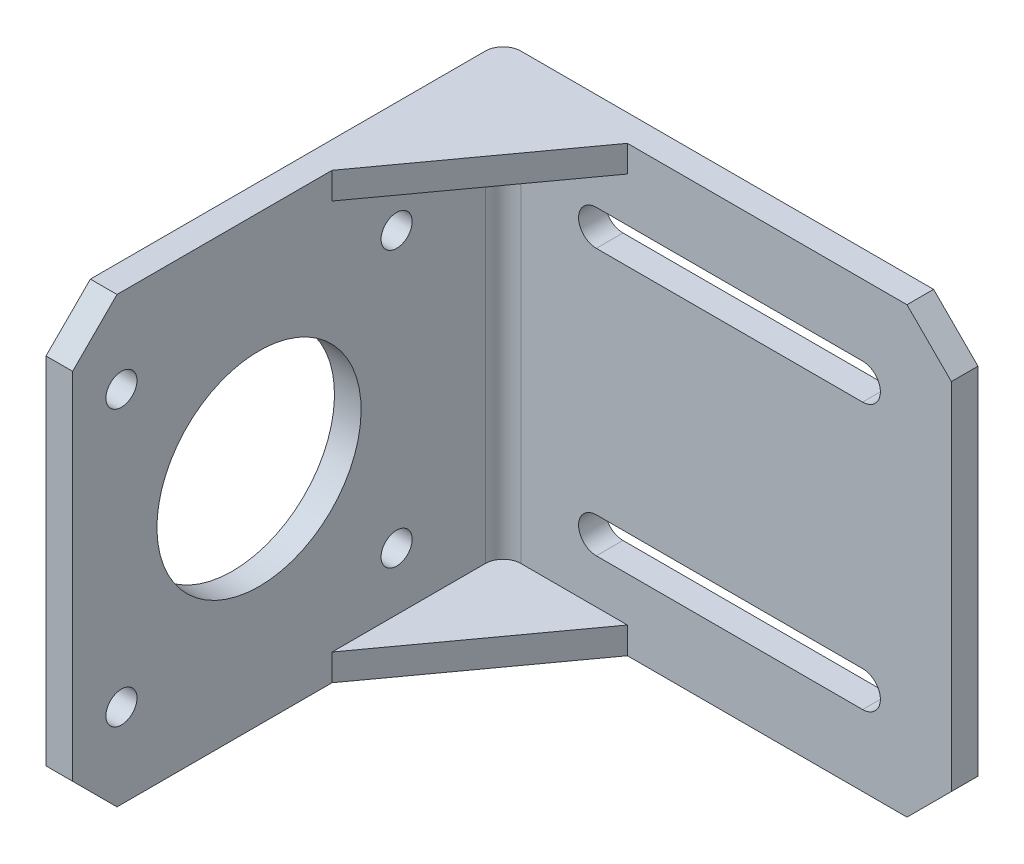
from build123d import *

# Parameters (mm, degrees)
SKETCH2_W           = 53.5
SKETCH2_H           = 50
BOSS_EXTRUDE1_DEPTH = 51.5
SKETCH3_W           = 50.5
SKETCH3_H           = 50
CUT_EXTRUDE1_DEPTH  = 48.5
CHAMFER1_SIZE       = 14
CHAMFER1_SIZE2      = 19.269346887
SKETCH4_W           = 48.5
SKETCH4_H           = 44
CUT_EXTRUDE2_DEPTH  = 50.5
SKETCH5_R           = 1.75
SKETCH5_R_2         = 11.5
CUT_EXTRUDE3_DEPTH  = 10
CUT_EXTRUDE4_DEPTH  = 10
CHAMFER2_SIZE       = 5
FILLET1_R           = 2


with BuildPart() as part:
    # Sketch2 → Boss-Extrude1 (new body)
    with BuildSketch(Plane.XY):
        Rectangle(SKETCH2_W, SKETCH2_H)
    extrude(amount=BOSS_EXTRUDE1_DEPTH)

    # Sketch3 → Cut-Extrude1 (cut)
    with BuildSketch(Plane.XY.offset(51.5)):
        with Locations((1.5, 0)):
            Rectangle(SKETCH3_W, SKETCH3_H)
    extrude(amount=-CUT_EXTRUDE1_DEPTH, mode=Mode.SUBTRACT)

    # Chamfer1
    chamfer1_edges = [part.edges().sort_by_distance(p)[0] for p in [
        (-23.75, 0, 3),
    ]]
    chamfer1_side = [part.faces().sort_by_distance(p)[0] for p in [
        (1.5, 0, 3),
    ]]
    chamfer(chamfer1_edges, length=CHAMFER1_SIZE, length2=CHAMFER1_SIZE2, reference=chamfer1_side[0])

    # Sketch4 → Cut-Extrude2 (cut)
    with BuildSketch(Plane(origin=(26.75, 0, 0), x_dir=(0, 0, -1), z_dir=(1, 0, 0))):
        with Locations((-27.25, 0)):
            Rectangle(SKETCH4_W, SKETCH4_H)
    extrude(amount=-CUT_EXTRUDE2_DEPTH, mode=Mode.SUBTRACT)

    # Sketch5 → Cut-Extrude3 (cut)
    with BuildSketch(Plane.ZY.offset(26.75)):
        with Locations((46, 15.5)):
            Circle(SKETCH5_R)
        with Locations((46, -15.5)):
            Circle(SKETCH5_R)
        with Locations((15, 15.5)):
            Circle(SKETCH5_R)
        with Locations((15, -15.5)):
            Circle(SKETCH5_R)
        with Locations((30.5, 0)):
            Circle(SKETCH5_R_2)
    extrude(amount=-CUT_EXTRUDE3_DEPTH, mode=Mode.SUBTRACT)

    # Sketch6 → Cut-Extrude4 (cut)
    with BuildSketch(Plane.XY.offset(3)):
        with BuildLine():
            Line((-13.25, 17), (16.75, 17))
            ThreePointArc((16.75, 17), (18.75, 15), (16.75, 13))
            Line((16.75, 13), (-13.25, 13))
            ThreePointArc((-13.25, 13), (-15.25, 15), (-13.25, 17))
        make_face()
        with BuildLine():
            Line((-13.25, -13), (16.75, -13))
            ThreePointArc((16.75, -13), (18.75, -15), (16.75, -17))
            Line((16.75, -17), (-13.25, -17))
            ThreePointArc((-13.25, -17), (-15.25, -15), (-13.25, -13))
        make_face()
    extrude(amount=-CUT_EXTRUDE4_DEPTH, mode=Mode.SUBTRACT)

    # Chamfer2
    chamfer2_edges = [part.edges().sort_by_distance(p)[0] for p in [
        (-25.25, -25, 51.5),
        (-25.25, 25, 51.5),
        (26.75, -25, 1.5),
        (26.75, 25, 1.5),
    ]]
    chamfer(chamfer2_edges, length=CHAMFER2_SIZE)

    # Fillet1
    fillet1_edges = [part.edges().sort_by_distance(p)[0] for p in [
        (-23.75, 0, 3),
        (-26.75, 0, 0),
    ]]
    fillet(fillet1_edges, radius=FILLET1_R)


solid = part.part
